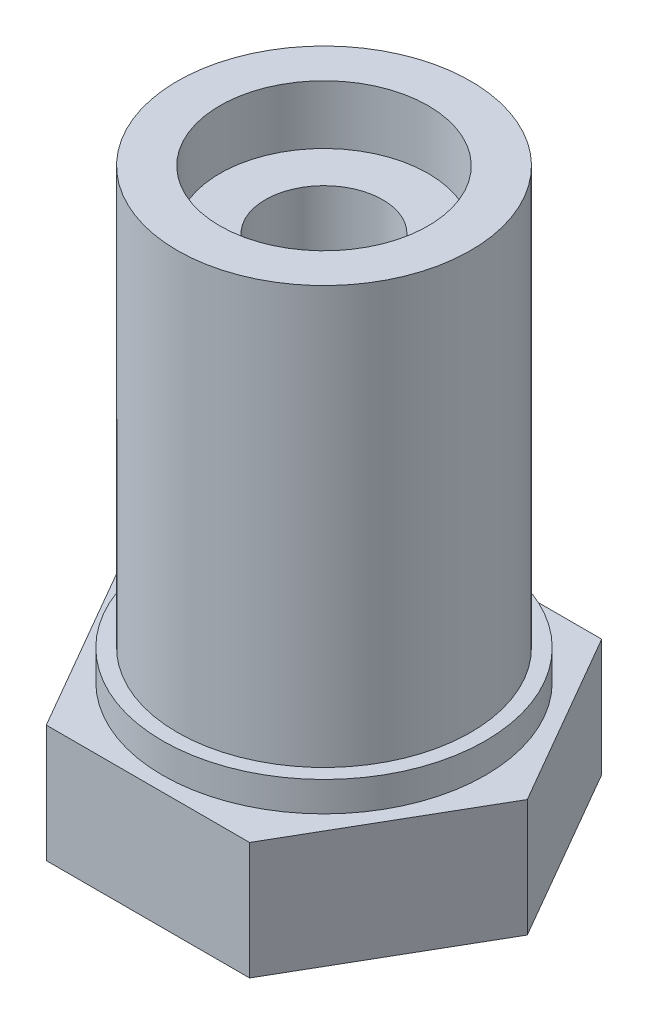
from build123d import *

# Parameters (mm, degrees)
BOSS_EXTRUDE1_DEPTH = 4
SKETCH2_R           = 5.500000049
SKETCH2_R_2         = 5.000000033
BOSS_EXTRUDE2_DEPTH = 1.016
SKETCH2_2_R         = 5.000000033
BOSS_EXTRUDE3_DEPTH = 15.24
SKETCH4_R           = 2.000000064
CUT_EXTRUDE2_DEPTH  = 22.311442936
SKETCH4_3_R         = 3.55
SKETCH4_3_R_2       = 2.000000064
CUT_EXTRUDE3_DEPTH  = 2


with BuildPart() as part:
    # Sketch1 → Boss-Extrude1 (new body)
    with BuildSketch(Plane(origin=(0, 0, 0), x_dir=(1, 0, 0), z_dir=(0, 1, 0))):
        Polygon((3.464101615, 6), (-3.464101615, 6), (-6.92820323, 0), (-3.464101615, -6), (3.464101615, -6), (6.92820323, 0), align=None)
    extrude(amount=BOSS_EXTRUDE1_DEPTH)

    # Sketch2 → Boss-Extrude2 (add)
    with BuildSketch(Plane(origin=(0, 4, 0), x_dir=(1, 0, 0), z_dir=(0, 1, 0))):
        Circle(SKETCH2_R)
        Circle(SKETCH2_R_2, mode=Mode.SUBTRACT)
    extrude(amount=BOSS_EXTRUDE2_DEPTH)

    # Sketch2_2 → Boss-Extrude3 (add)
    with BuildSketch(Plane(origin=(0, 4, 0), x_dir=(1, 0, 0), z_dir=(0, 1, 0))):
        Circle(SKETCH2_2_R)
    extrude(amount=BOSS_EXTRUDE3_DEPTH)

    # Sketch4 → Cut-Extrude2 (cut, through all)
    with BuildSketch(Plane(origin=(0, 19.24, 0), x_dir=(1, 0, 0), z_dir=(0, 1, 0))):
        Circle(SKETCH4_R)
    extrude(amount=-CUT_EXTRUDE2_DEPTH, mode=Mode.SUBTRACT)

    # Sketch4_3 → Cut-Extrude3 (cut)
    with BuildSketch(Plane(origin=(0, 19.24, 0), x_dir=(1, 0, 0), z_dir=(0, 1, 0))):
        Circle(SKETCH4_3_R)
        Circle(SKETCH4_3_R_2, mode=Mode.SUBTRACT)
    extrude(amount=-CUT_EXTRUDE3_DEPTH, mode=Mode.SUBTRACT)


solid = part.part
